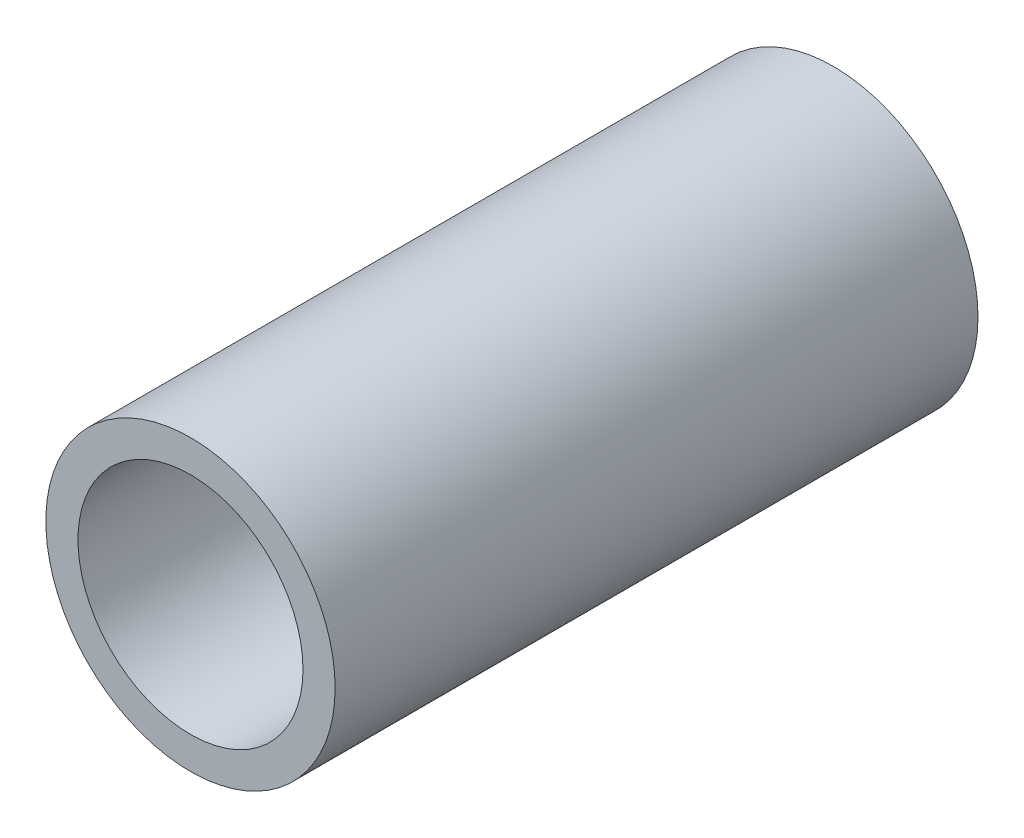
from build123d import *

# Parameters (mm, degrees)
SKETCH1_R           = 9
SKETCH1_R_2         = 7
BOSS_EXTRUDE1_DEPTH = 20


with BuildPart() as part:
    # Sketch1 → Boss-Extrude1 (new body, symmetric)
    with BuildSketch(Plane.XY):
        Circle(SKETCH1_R)
        Circle(SKETCH1_R_2, mode=Mode.SUBTRACT)
    extrude(amount=BOSS_EXTRUDE1_DEPTH, both=True)


solid = part.part
